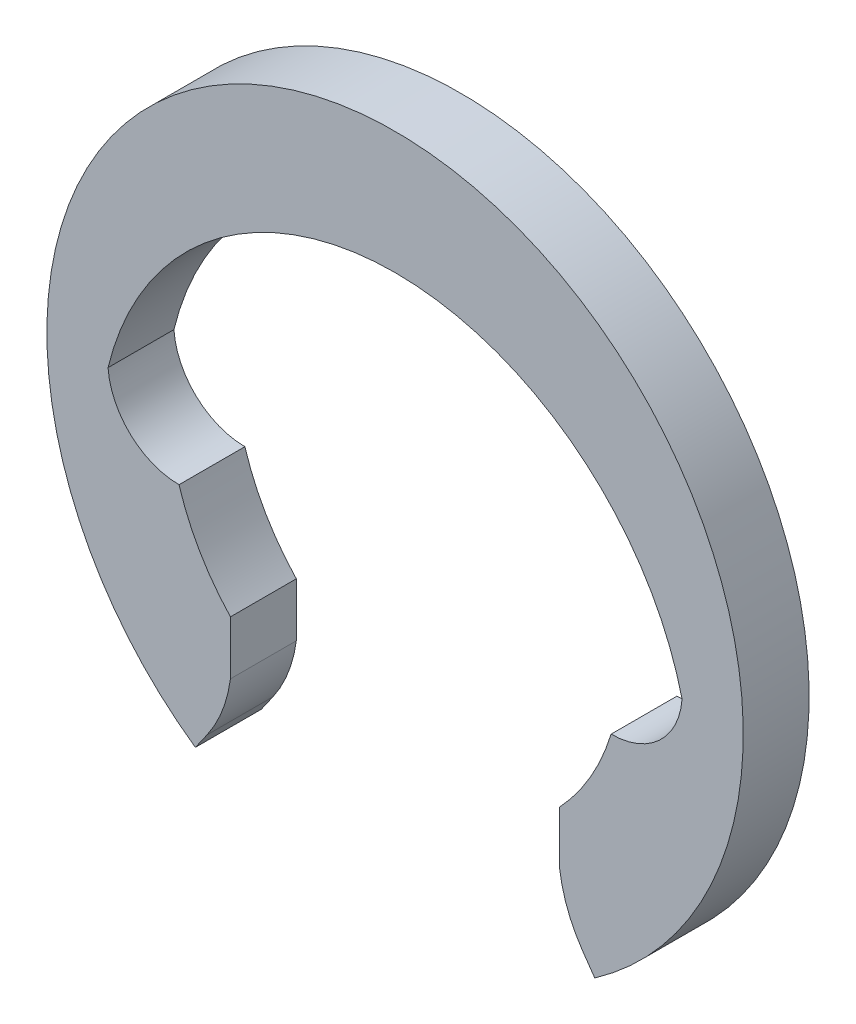
from build123d import *

# Parameters (mm, degrees)
BOSS_EXTRUDE1_DEPTH = 0.7


with BuildPart() as part:
    # Sketch2 → Boss-Extrude1 (new body)
    with BuildSketch(Plane.XY):
        with BuildLine():
            Line((-1.749408131, -2.213288218), (-1.749408131, -1.928162702))
            Line((-1.749408131, -1.928162702), (-1.749408131, -1.643037185))
            ThreePointArc((-1.749408131, -1.643037185), (-2.076764231, -1.202934049), (-2.295648057, -0.7))
            ThreePointArc((-2.295648057, -0.7), (-2.810198067, -0.498040533), (-3.05, 0))
            ThreePointArc((-3.05, 0), (0, 2.4), (3.05, 0))
            ThreePointArc((3.05, 0), (2.810198067, -0.498040533), (2.295648057, -0.7))
            ThreePointArc((2.295648057, -0.7), (2.076764231, -1.202934049), (1.749408131, -1.643037185))
            Line((1.749408131, -1.643037185), (1.749408131, -1.928162702))
            Line((1.749408131, -1.928162702), (1.749408131, -2.213288218))
            ThreePointArc((1.749408131, -2.213288218), (1.835013797, -2.54834932), (1.99795792, -2.853379621))
            Line((1.99795792, -2.853379621), (2.122232814, -3.030862564))
            ThreePointArc((2.122232814, -3.030862564), (0, 3.7), (-2.122232814, -3.030862564))
            Line((-2.122232814, -3.030862564), (-1.99795792, -2.853379621))
            ThreePointArc((-1.99795792, -2.853379621), (-1.835013797, -2.54834932), (-1.749408131, -2.213288218))
        make_face()
    extrude(amount=BOSS_EXTRUDE1_DEPTH)


solid = part.part
